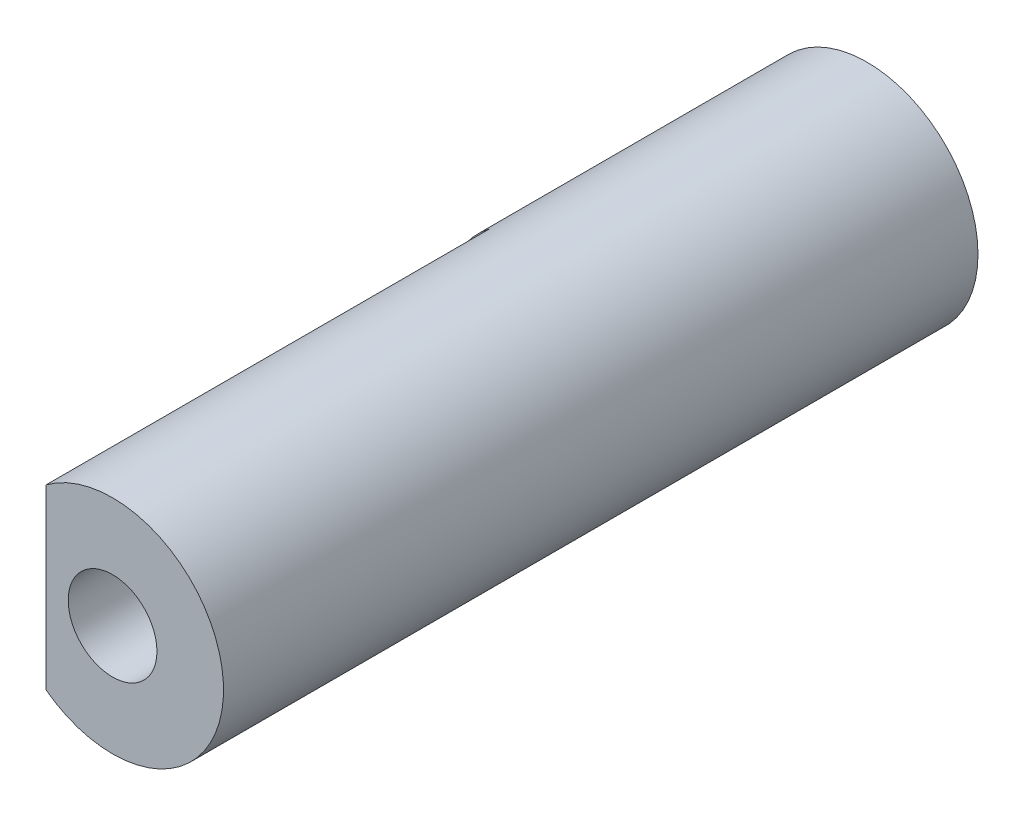
from build123d import *

# Parameters (mm, degrees)
SKETCH1_R           = 2.5
BOSS_EXTRUDE1_DEPTH = 17
SKETCH2_W           = 1
SKETCH2_H           = 5
CUT_EXTRUDE1_DEPTH  = 10
SKETCH3_R           = 1
CUT_EXTRUDE2_DEPTH  = 2


with BuildPart() as part:
    # Sketch1 → Boss-Extrude1 (new body)
    with BuildSketch(Plane.XY):
        Circle(SKETCH1_R)
    extrude(amount=BOSS_EXTRUDE1_DEPTH)

    # Sketch2 → Cut-Extrude1 (cut)
    with BuildSketch(Plane.XY.offset(17)):
        with Locations((-2, 0)):
            Rectangle(SKETCH2_W, SKETCH2_H)
    extrude(amount=-CUT_EXTRUDE1_DEPTH, mode=Mode.SUBTRACT)

    # Sketch3 → Cut-Extrude2 (cut)
    with BuildSketch(Plane.XY.offset(17)):
        Circle(SKETCH3_R)
    extrude(amount=-CUT_EXTRUDE2_DEPTH, mode=Mode.SUBTRACT)


solid = part.part
